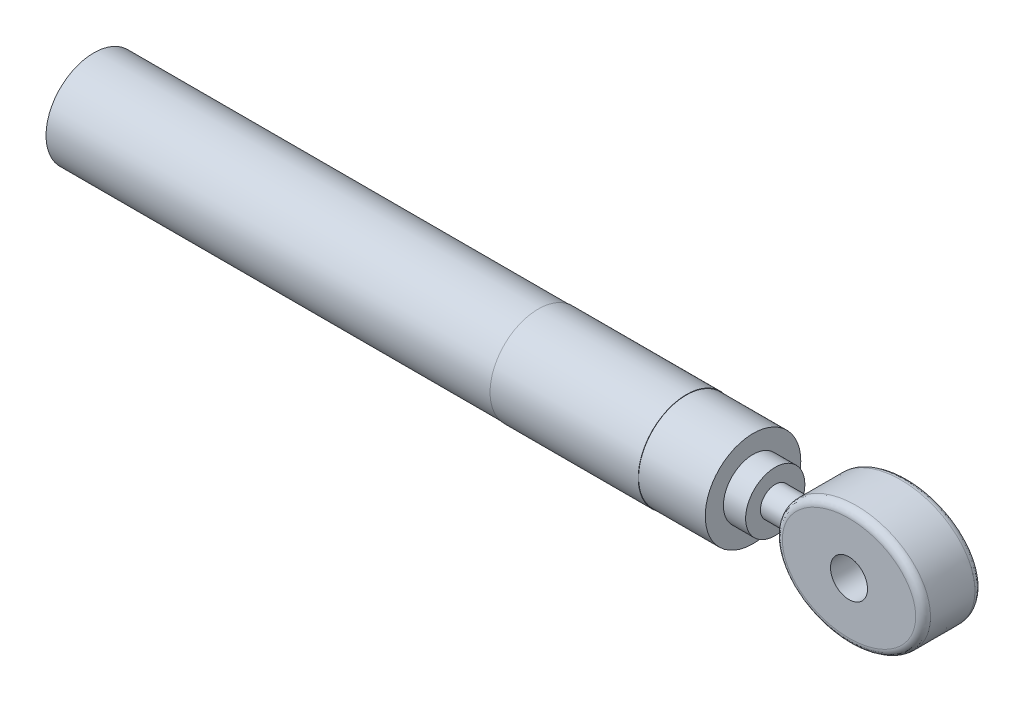
from build123d import *

# Parameters (mm, degrees)
SKETCH1_R                = 6.5
BOSS_EXTRUDE1_DEPTH      = 20
SKETCH2_R                = 6.45
BOSS_EXTRUDE2_DEPTH      = 9
SKETCH3_R                = 4
BOSS_EXTRUDE3_DEPTH      = 3
BOSS_EXTRUDE4_DEPTH      = 4
BOSS_EXTRUDE4_DEPTH_BACK = 4
SKETCH4_RX               = 10
SKETCH4_RY               = 8
FILLET2_R                = 1
SKETCH5_R                = 2
BOSS_EXTRUDE5_DEPTH      = 11.5
SKETCH8_R                = 2.5
CUT_EXTRUDE1_DEPTH       = 58.495545747
BOSS_EXTRUDE6_START      = 60
SKETCH9_R                = 6.45
BOSS_EXTRUDE6_DEPTH      = 60
SKETCH10_R               = 2
CUT_EXTRUDE2_DEPTH       = 10
BOSS_EXTRUDE7_START      = 1
SKETCH11_R               = 3.674860137
SKETCH11_R_2             = 2
BOSS_EXTRUDE7_DEPTH      = 1


with BuildPart() as part:
    # Sketch1 → Boss-Extrude1 (new body)
    with BuildSketch(Plane(origin=(0, 0, 0), x_dir=(0, 0, -1), z_dir=(1, 0, 0))):
        Circle(SKETCH1_R)
    extrude(amount=BOSS_EXTRUDE1_DEPTH)

    # Sketch2 → Boss-Extrude2 (add)
    with BuildSketch(Plane(origin=(20, 0, 0), x_dir=(0, 0, -1), z_dir=(1, 0, 0))):
        Circle(SKETCH2_R)
    extrude(amount=BOSS_EXTRUDE2_DEPTH)

    # Sketch3 → Boss-Extrude3 (add)
    with BuildSketch(Plane(origin=(29, 0, 0), x_dir=(0, 0, -1), z_dir=(1, 0, 0))):
        Circle(SKETCH3_R)
    extrude(amount=BOSS_EXTRUDE3_DEPTH)



with BuildPart() as body_2:
    # Sketch4 → Boss-Extrude4 (new, two sides: drawn at the far end of the back side and taken through both)
    with BuildSketch(Plane.XY.offset(-BOSS_EXTRUDE4_DEPTH_BACK)):
        with Locations(Location((45.959697712, 0), (0, 0, 180))):
            Ellipse(SKETCH4_RX, SKETCH4_RY)
    extrude(amount=BOSS_EXTRUDE4_DEPTH + BOSS_EXTRUDE4_DEPTH_BACK)

    # Fillet2
    fillet2_edges = [body_2.edges().sort_by_distance(p)[0] for p in [
        (55.959697589, 0.00125173, -4),
        (55.959697589, 0.00125173, 4),
    ]]
    fillet(fillet2_edges, radius=FILLET2_R)


with BuildPart() as part_1:
    add(part.part)

    add(body_2.part)  # Boss-Extrude5 merges body 2
    # Sketch5 → Boss-Extrude5 (add)
    with BuildSketch(Plane(origin=(32, 0, 0), x_dir=(0, 0, -1), z_dir=(1, 0, 0))):
        Circle(SKETCH5_R)
    extrude(amount=BOSS_EXTRUDE5_DEPTH)

    # Sketch8 → Cut-Extrude1 (cut, through all)
    with BuildSketch(Plane.XY.offset(4)):
        with Locations((45.959697644, 0)):
            Circle(SKETCH8_R)
    extrude(amount=-CUT_EXTRUDE1_DEPTH, mode=Mode.SUBTRACT)

    # Sketch9 → Boss-Extrude6 (add)
    with BuildSketch(Plane.ZY.offset(BOSS_EXTRUDE6_START)):
        Circle(SKETCH9_R)
    extrude(amount=-BOSS_EXTRUDE6_DEPTH)

    # Sketch10 → Cut-Extrude2 (cut)
    with BuildSketch(Plane.ZY.offset(60)):
        Circle(SKETCH10_R)
    extrude(amount=-CUT_EXTRUDE2_DEPTH, mode=Mode.SUBTRACT)

    # Sketch11 → Boss-Extrude7 (add)
    with BuildSketch(Plane.ZY.offset(60).offset(BOSS_EXTRUDE7_START)):
        Circle(SKETCH11_R)
        Circle(SKETCH11_R_2, mode=Mode.SUBTRACT)
    extrude(amount=-BOSS_EXTRUDE7_DEPTH)


solid = part_1.part
